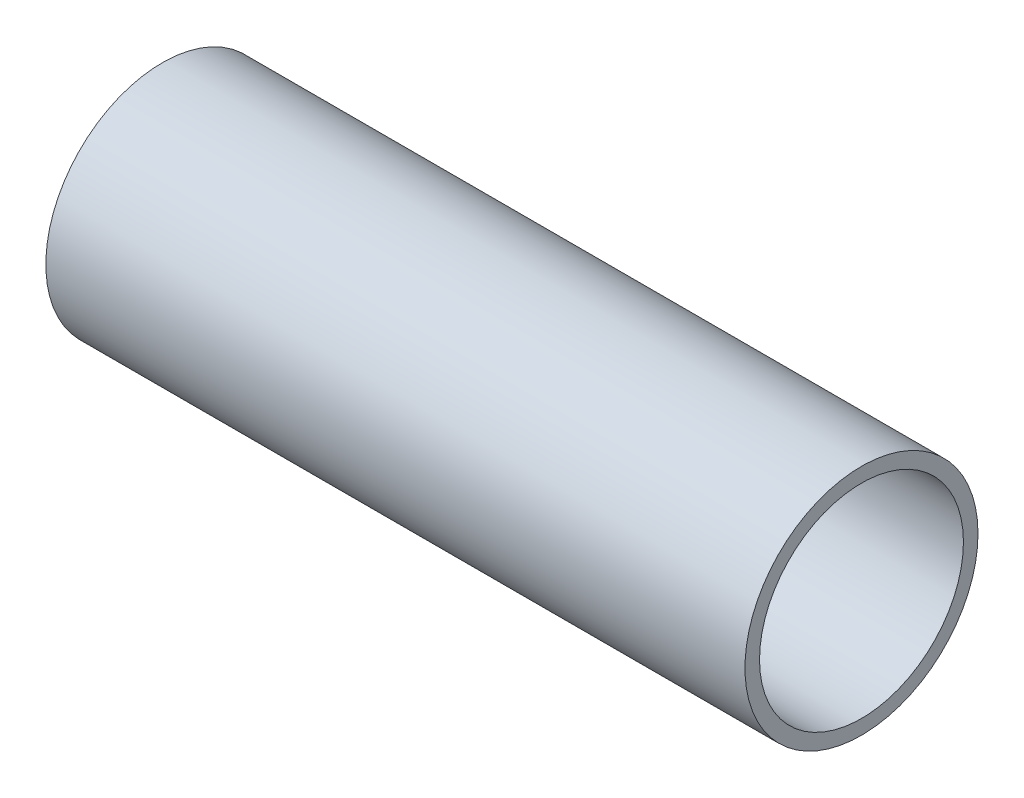
from build123d import *

# Parameters (mm, degrees)
SKETCH3_R           = 25.4
SKETCH3_R_2         = 22.225
BOSS_EXTRUDE1_DEPTH = 152.4


with BuildPart() as part:
    # Sketch3 → Boss-Extrude1 (new body)
    with BuildSketch(Plane(origin=(0, 0, 0), x_dir=(0, 0, -1), z_dir=(1, 0, 0))):
        Circle(SKETCH3_R)
        Circle(SKETCH3_R_2, mode=Mode.SUBTRACT)
    extrude(amount=BOSS_EXTRUDE1_DEPTH)


solid = part.part
